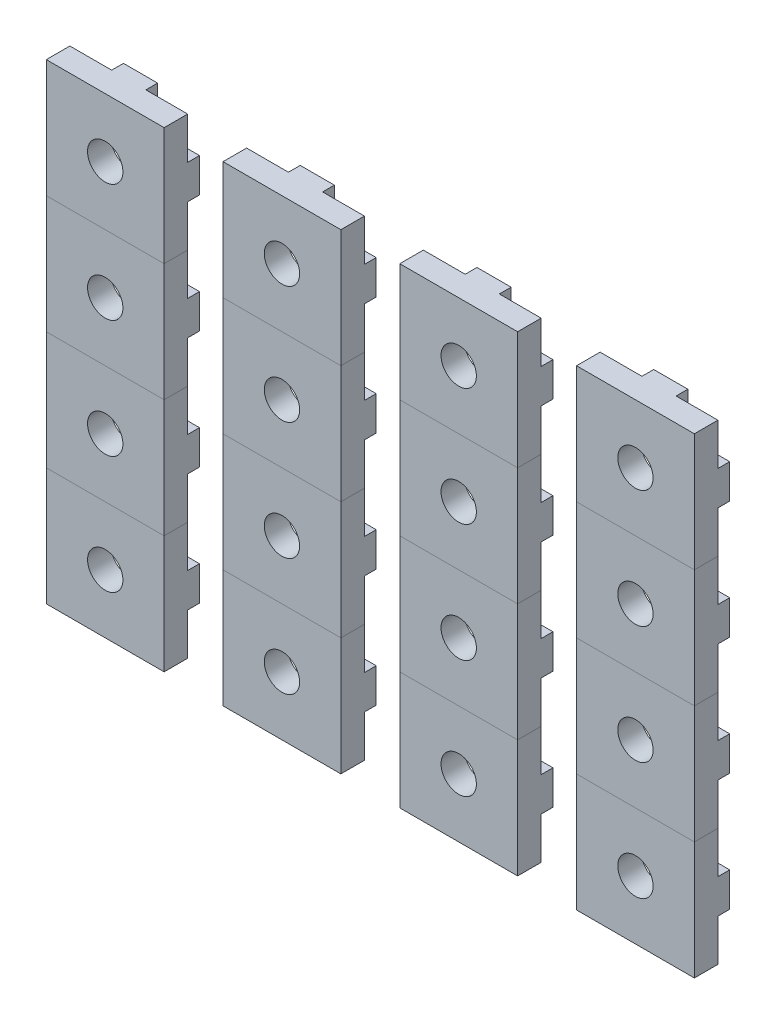
from build123d import *

# Parameters (mm, degrees)
SKETCH1_W                = 10
SKETCH1_H                = 10
SKETCH1_R                = 1.5
MAIN_DEPTH               = 2
ANTIROTATIONSYSTEM_DEPTH = 1
CIRPATTERN1_COUNT        = 4
LPATTERN1_COUNT          = 4
LPATTERN1_PITCH          = 10
LPATTERN2_COUNT          = 4
LPATTERN2_PITCH          = 15


with BuildPart() as part:
    # Sketch1 → Main (new body)
    with BuildSketch(Plane.XY):
        Rectangle(SKETCH1_W, SKETCH1_H)
        Circle(SKETCH1_R, mode=Mode.SUBTRACT)
    extrude(amount=MAIN_DEPTH)

    # Sketch2 → AntiRotationSystem (add)
    with BuildSketch(Plane(origin=(0, 0, 0), x_dir=(-1, 0, 0), z_dir=(0, 0, -1))):
        Polygon((-5, 1.45), (-3.9, 1.45), (-3.9, 3), (-2.1, 0.95), (-2.1, -0.95), (-3.9, -3), (-3.9, -1.45), (-5, -1.45), align=None)
    antirotationsystem = extrude(amount=ANTIROTATIONSYSTEM_DEPTH)

    # CirPattern1: AntiRotationSystem ×4 about axis
    cirpattern1_axis = Axis((0, 0, 0), (0, 0, 1))
    for i in range(1, CIRPATTERN1_COUNT):
        add(antirotationsystem.rotate(cirpattern1_axis, i * 360 / CIRPATTERN1_COUNT))


with BuildPart() as lpattern1_1:
    # LPattern1: pattern copy
    add(part.part.moved(Location(Vector(0, -1, 0) * (1 * LPATTERN1_PITCH))))


with BuildPart() as lpattern1_2:
    # LPattern1: pattern copy
    add(part.part.moved(Location(Vector(0, -1, 0) * (2 * LPATTERN1_PITCH))))


with BuildPart() as lpattern1_3:
    # LPattern1: pattern copy
    add(part.part.moved(Location(Vector(0, -1, 0) * (3 * LPATTERN1_PITCH))))


with BuildPart() as lpattern2_1:
    # LPattern2: pattern copy
    add(part.part.moved(Location(Vector(-1, 0, 0) * (1 * LPATTERN2_PITCH))))


with BuildPart() as lpattern2_2:
    # LPattern2: pattern copy
    add(part.part.moved(Location(Vector(-1, 0, 0) * (2 * LPATTERN2_PITCH))))


with BuildPart() as lpattern2_3:
    # LPattern2: pattern copy
    add(part.part.moved(Location(Vector(-1, 0, 0) * (3 * LPATTERN2_PITCH))))


with BuildPart() as lpattern2_4:
    # LPattern2: pattern copy
    add(lpattern1_1.part.moved(Location(Vector(-1, 0, 0) * (1 * LPATTERN2_PITCH))))


with BuildPart() as lpattern2_5:
    # LPattern2: pattern copy
    add(lpattern1_1.part.moved(Location(Vector(-1, 0, 0) * (2 * LPATTERN2_PITCH))))


with BuildPart() as lpattern2_6:
    # LPattern2: pattern copy
    add(lpattern1_1.part.moved(Location(Vector(-1, 0, 0) * (3 * LPATTERN2_PITCH))))


with BuildPart() as lpattern2_7:
    # LPattern2: pattern copy
    add(lpattern1_2.part.moved(Location(Vector(-1, 0, 0) * (1 * LPATTERN2_PITCH))))


with BuildPart() as lpattern2_8:
    # LPattern2: pattern copy
    add(lpattern1_2.part.moved(Location(Vector(-1, 0, 0) * (2 * LPATTERN2_PITCH))))


with BuildPart() as lpattern2_9:
    # LPattern2: pattern copy
    add(lpattern1_2.part.moved(Location(Vector(-1, 0, 0) * (3 * LPATTERN2_PITCH))))


with BuildPart() as lpattern2_10:
    # LPattern2: pattern copy
    add(lpattern1_3.part.moved(Location(Vector(-1, 0, 0) * (1 * LPATTERN2_PITCH))))


with BuildPart() as lpattern2_11:
    # LPattern2: pattern copy
    add(lpattern1_3.part.moved(Location(Vector(-1, 0, 0) * (2 * LPATTERN2_PITCH))))


with BuildPart() as lpattern2_12:
    # LPattern2: pattern copy
    add(lpattern1_3.part.moved(Location(Vector(-1, 0, 0) * (3 * LPATTERN2_PITCH))))


solid = Compound([part.part, lpattern1_1.part, lpattern1_2.part, lpattern1_3.part, lpattern2_1.part, lpattern2_2.part, lpattern2_3.part, lpattern2_4.part, lpattern2_5.part, lpattern2_6.part, lpattern2_7.part, lpattern2_8.part, lpattern2_9.part, lpattern2_10.part, lpattern2_11.part, lpattern2_12.part])
